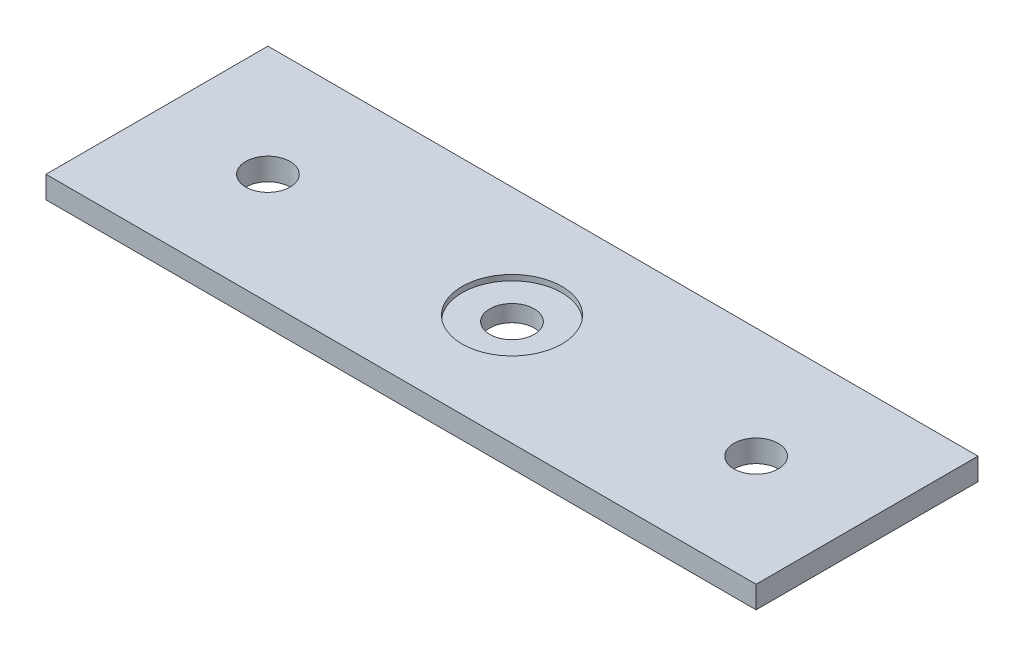
from build123d import *

# Parameters (mm, degrees)
SKETCH8_W           = 203.2
SKETCH8_H           = 63.5
BOSS_EXTRUDE1_DEPTH = 6.35
SKETCH9_R           = 14.2875
CUT_EXTRUDE2_DEPTH  = 1.5875
SKETCH10_R          = 6.35
CUT_EXTRUDE3_DEPTH  = 5.7625
SKETCH11_R          = 6.35
CUT_EXTRUDE4_DEPTH  = 7.35


with BuildPart() as part:
    # Sketch8 → Boss-Extrude1 (new body)
    with BuildSketch(Plane(origin=(0, 0, 0), x_dir=(1, 0, 0), z_dir=(0, 1, 0))):
        with Locations((-101.6, 31.75)):
            Rectangle(SKETCH8_W, SKETCH8_H)
    extrude(amount=BOSS_EXTRUDE1_DEPTH)

    # Sketch9 → Cut-Extrude2 (cut)
    with BuildSketch(Plane(origin=(0, 6.35, 0), x_dir=(1, 0, 0), z_dir=(0, 1, 0))):
        with Locations((-101.6, 31.75)):
            Circle(SKETCH9_R)
    extrude(amount=-CUT_EXTRUDE2_DEPTH, mode=Mode.SUBTRACT)

    # Sketch10 → Cut-Extrude3 (cut, through all)
    with BuildSketch(Plane(origin=(0, 4.7625, 0), x_dir=(1, 0, 0), z_dir=(0, 1, 0))):
        with Locations((-101.6, 31.75)):
            Circle(SKETCH10_R)
    extrude(amount=-CUT_EXTRUDE3_DEPTH, mode=Mode.SUBTRACT)

    # Sketch11 → Cut-Extrude4 (cut, through all)
    with BuildSketch(Plane(origin=(0, 6.35, 0), x_dir=(1, 0, 0), z_dir=(0, 1, 0))):
        with Locations((-171.45, 31.75)):
            Circle(SKETCH11_R)
        with Locations((-31.75, 31.75)):
            Circle(SKETCH11_R)
    extrude(amount=-CUT_EXTRUDE4_DEPTH, mode=Mode.SUBTRACT)


solid = part.part
